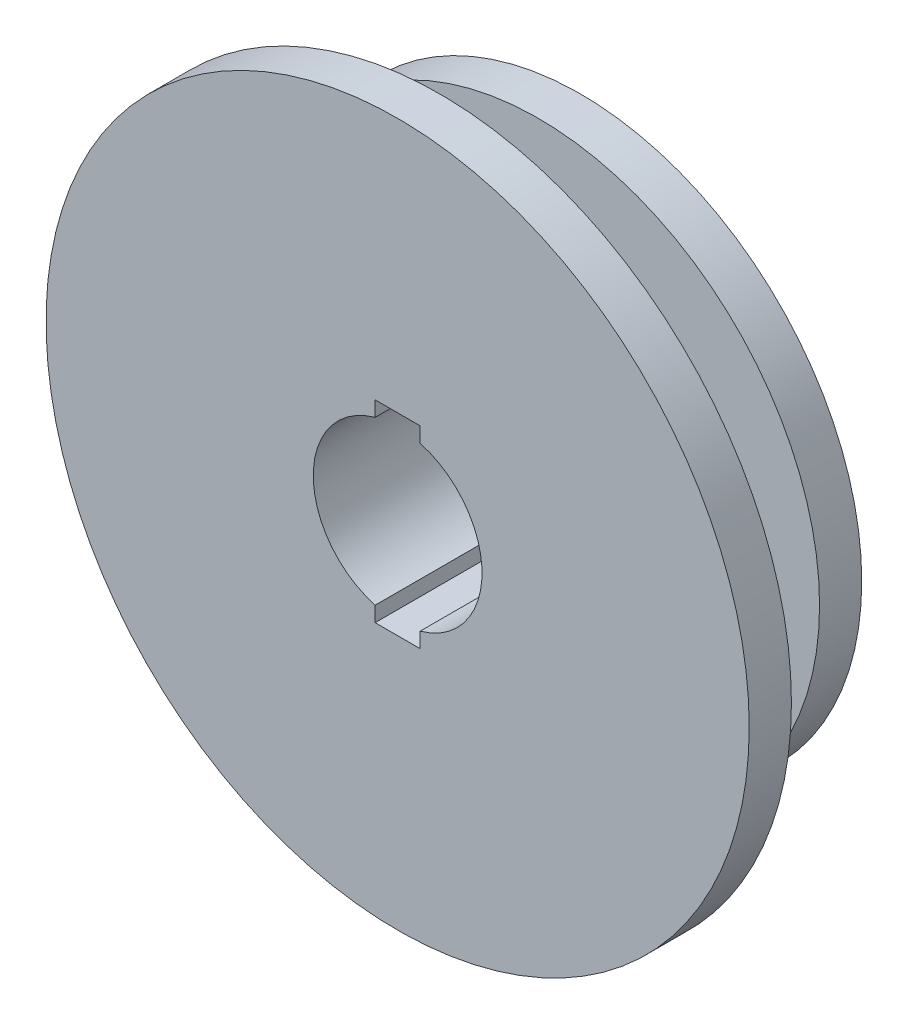
from build123d import *

# Parameters (mm, degrees)
CUT_EXTRUDE1_DEPTH = 100
CIRPATTERN1_COUNT  = 2


with BuildPart() as part:
    # Sketch2 → Revolve1 (revolve)
    with BuildSketch(Plane(origin=(0, 0, 0), x_dir=(0, 0, -1), z_dir=(1, 0, 0))):
        Polygon((-31.942129743, 65.824496016), (-31.942129743, 255.824496016), (-1.942129743, 255.824496016), (-1.942129743, 95.824496016), (68.057870257, 95.824496016), (68.057870257, 205.824496016), (98.057870257, 205.824496016), (98.057870257, 35.824496016), (68.057870257, 35.824496016), (68.057870257, 65.824496016), align=None)
    revolve(axis=Axis((0, 5.824496016, 0), (0, 0, -1)))

    # Sketch3 → Cut-Extrude1 (cut)
    with BuildSketch(Plane.XY.offset(31.942129743)):
        with BuildLine():
            Line((16, 63.651825195), (16, 74.437748913))
            Line((16, 74.437748913), (-16, 74.437748913))
            Line((-16, 74.437748913), (-16, 63.651825195))
            ThreePointArc((-16, 63.651825195), (0, 65.824496016), (16, 63.651825195))
        make_face()
    cut_extrude1 = extrude(amount=-CUT_EXTRUDE1_DEPTH, mode=Mode.SUBTRACT)

    # CirPattern1: Cut-Extrude1 ×2 about axis
    cirpattern1_axis = Axis((0, 5.824496016, 0), (0, 0, 1))
    for i in range(1, CIRPATTERN1_COUNT):
        add(cut_extrude1.rotate(cirpattern1_axis, i * 360 / CIRPATTERN1_COUNT), mode=Mode.SUBTRACT)


solid = part.part
